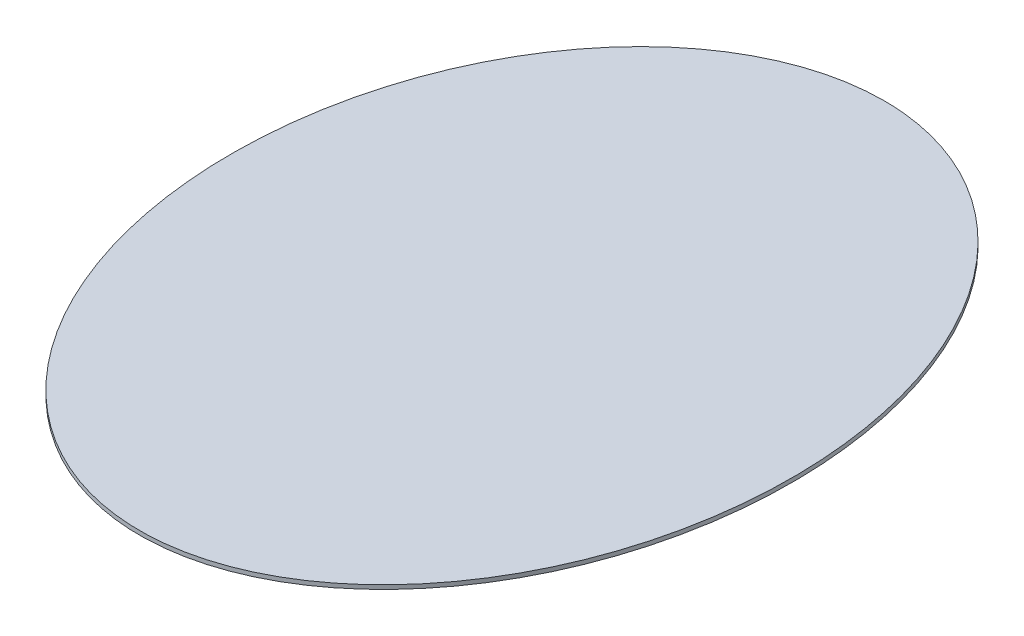
from build123d import *

# Parameters (mm, degrees)
SKETCH1_RX          = 365
SKETCH1_RY          = 275
BOSS_EXTRUDE1_DEPTH = 4


with BuildPart() as part:
    # Sketch1 → Boss-Extrude1 (new body)
    with BuildSketch(Plane(origin=(0, 0, 0), x_dir=(1, 0, 0), z_dir=(0, 1, 0))):
        with Locations(Location((0, 0), (0, 0, 90))):
            Ellipse(SKETCH1_RX, SKETCH1_RY)
    extrude(amount=BOSS_EXTRUDE1_DEPTH)


solid = part.part
